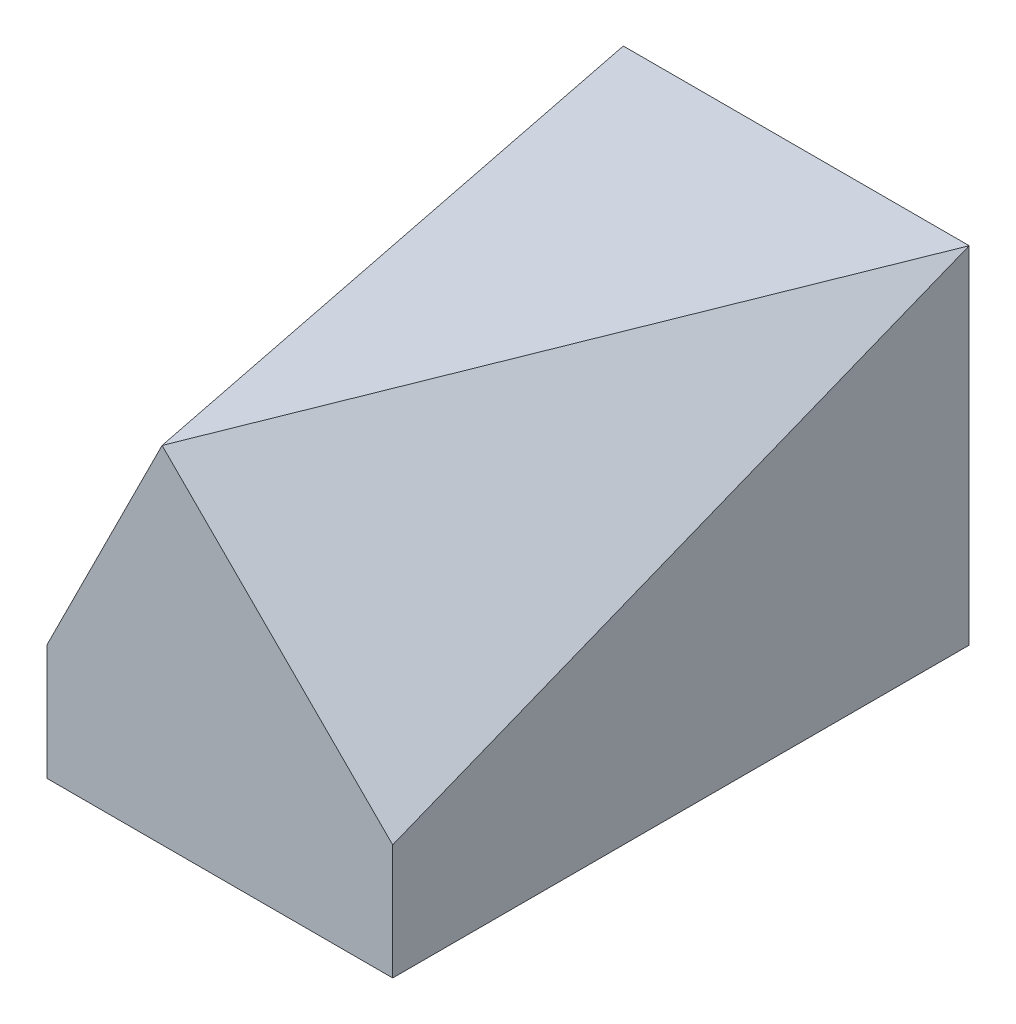
from build123d import *

# Parameters (mm, degrees)
SKETCH_1_W          = 15
SKETCH_1_H          = 25
EXTRUDE_1_DEPTH     = 15
SKETCH_4_W          = 33.460320445
SKETCH_4_H          = 26.687965621
CUT_EXTRUDE_1_DEPTH = 15
SKETCH_5_W          = 41.021028331
SKETCH_5_H          = 23.23593172
CUT_EXTRUDE_2_DEPTH = 15


with BuildPart() as part:
    # 草圖1 → 填料-伸長1 (new body)
    with BuildSketch(Plane(origin=(0, 0, 0), x_dir=(1, 0, 0), z_dir=(0, 1, 0))):
        Rectangle(SKETCH_1_W, SKETCH_1_H)
    extrude(amount=EXTRUDE_1_DEPTH)

    # 草圖4 → 除料-伸長1 (cut)
    with BuildSketch(Plane(origin=(-9.689922481, 4.84496124, 1.937984496), x_dir=(0.157499846, -0.078749923, 0.984374039), z_dir=(-0.880450906, 0.440225453, 0.176090181))):
        with Locations((1.566467167, 5.33065366)):
            Rectangle(SKETCH_4_W, SKETCH_4_H)
    extrude(amount=CUT_EXTRUDE_1_DEPTH, mode=Mode.SUBTRACT)

    # 草圖5 → 除料-伸長2 (cut)
    with BuildSketch(Plane(origin=(8.101851852, 8.101851852, 3.240740741), x_dir=(-0.19245009, -0.19245009, 0.962250449), z_dir=(-0.680413817, -0.680413817, -0.272165527))):
        with Locations((-1.846019689, 5.465840721)):
            Rectangle(SKETCH_5_W, SKETCH_5_H)
    extrude(amount=-CUT_EXTRUDE_2_DEPTH, mode=Mode.SUBTRACT)


solid = part.part
